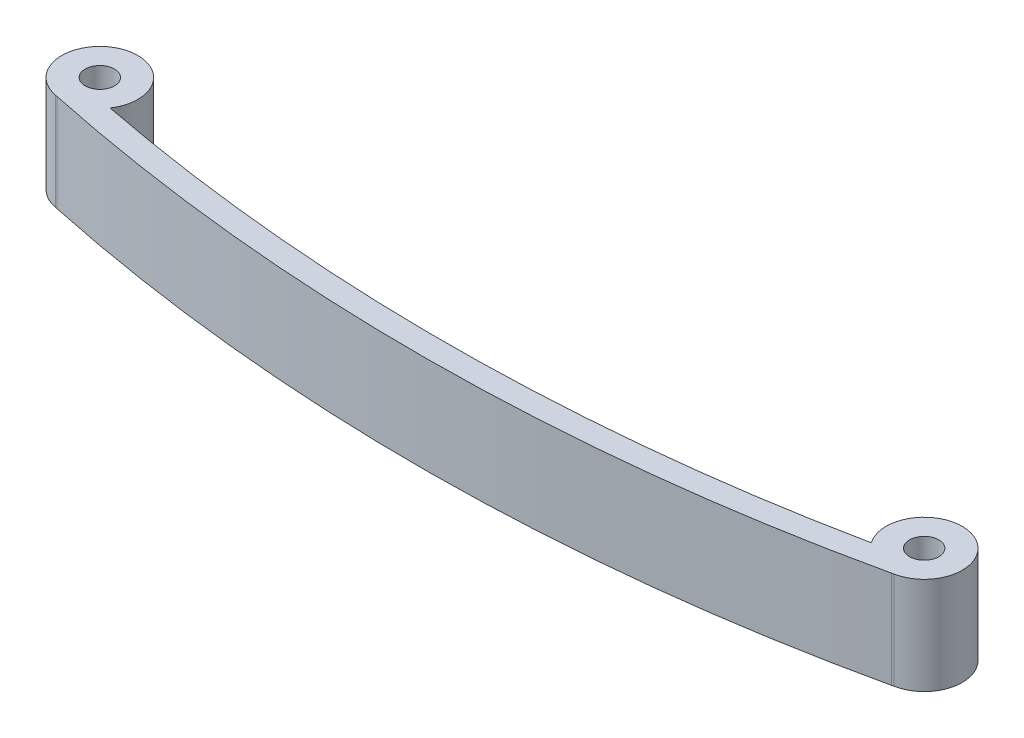
from build123d import *

# Parameters (mm, degrees)
SKETCH1_R           = 1.25
BOSS_EXTRUDE1_DEPTH = 8.3


with BuildPart() as part:
    # Sketch1 → Boss-Extrude1 (new body)
    with BuildSketch(Plane(origin=(0, 0, 0), x_dir=(1, 0, 0), z_dir=(0, 1, 0))):
        with BuildLine():
            Line((35.434172296, 1.287491613), (35.622727971, 1.3307936))
            ThreePointArc((35.622727971, 1.3307936), (36.223294794, 7.531563888), (32.32905872, 2.668935167))
            ThreePointArc((32.32905872, 2.668935167), (0.027157554, -0.697665471), (-32.309217612, 2.319893124))
            ThreePointArc((-32.309217612, 2.319893124), (-36.261610619, 7.13771657), (-35.575715837, 0.943979283))
            Line((-35.575715837, 0.943979283), (-35.413230424, 0.907951956))
            ThreePointArc((-35.413230424, 0.907951956), (0.030803418, -2.69767479), (35.434172296, 1.287491613))
        make_face()
        with Locations((-35, 4.142580739)):
            Circle(SKETCH1_R, mode=Mode.SUBTRACT)
        with Locations((35, 4.520575704)):
            Circle(SKETCH1_R, mode=Mode.SUBTRACT)
    extrude(amount=BOSS_EXTRUDE1_DEPTH)


solid = part.part
